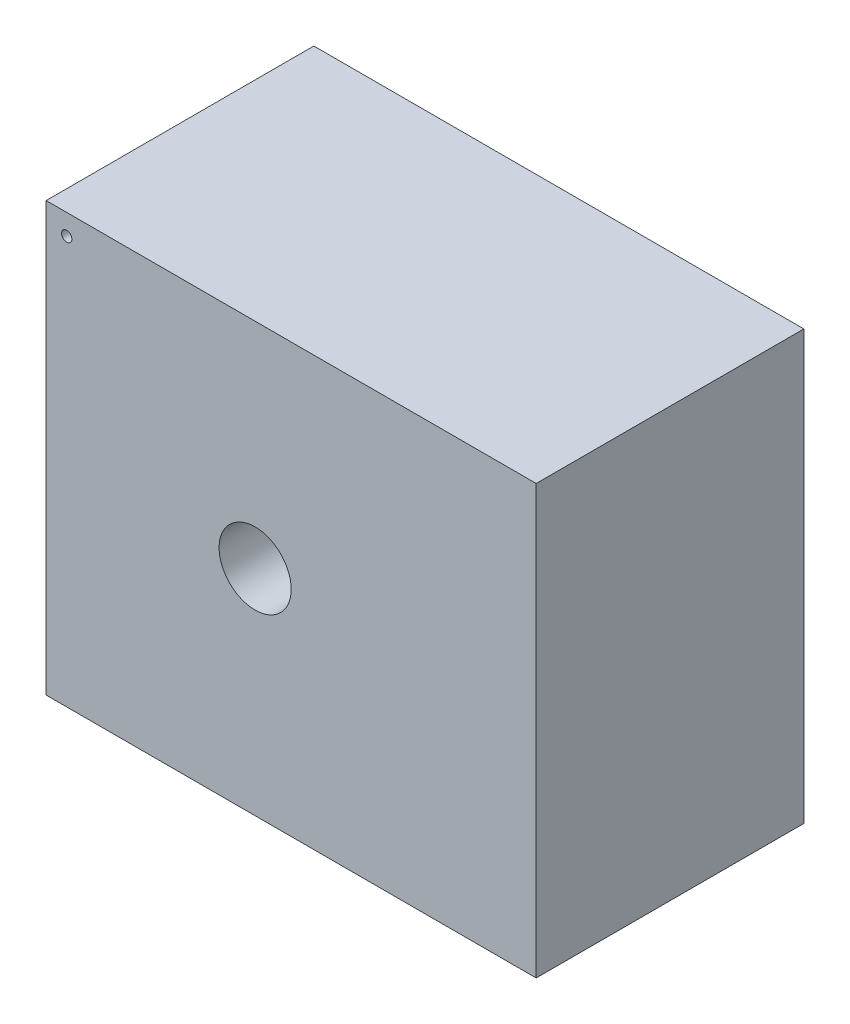
from build123d import *

# Parameters (mm, degrees)
SKETCH1_W           = 238
SKETCH1_H           = 208
SKETCH1_R           = 17.5
SKETCH1_R_2         = 2.5
BOSS_EXTRUDE1_DEPTH = 130


with BuildPart() as part:
    # Sketch1 → Boss-Extrude1 (new body)
    with BuildSketch(Plane.XY):
        with Locations((154, 104)):
            Rectangle(SKETCH1_W, SKETCH1_H)
        with Locations((136.5, 104)):
            Circle(SKETCH1_R, mode=Mode.SUBTRACT)
        with Locations((45, 198)):
            Circle(SKETCH1_R_2, mode=Mode.SUBTRACT)
    extrude(amount=-BOSS_EXTRUDE1_DEPTH)


solid = part.part
